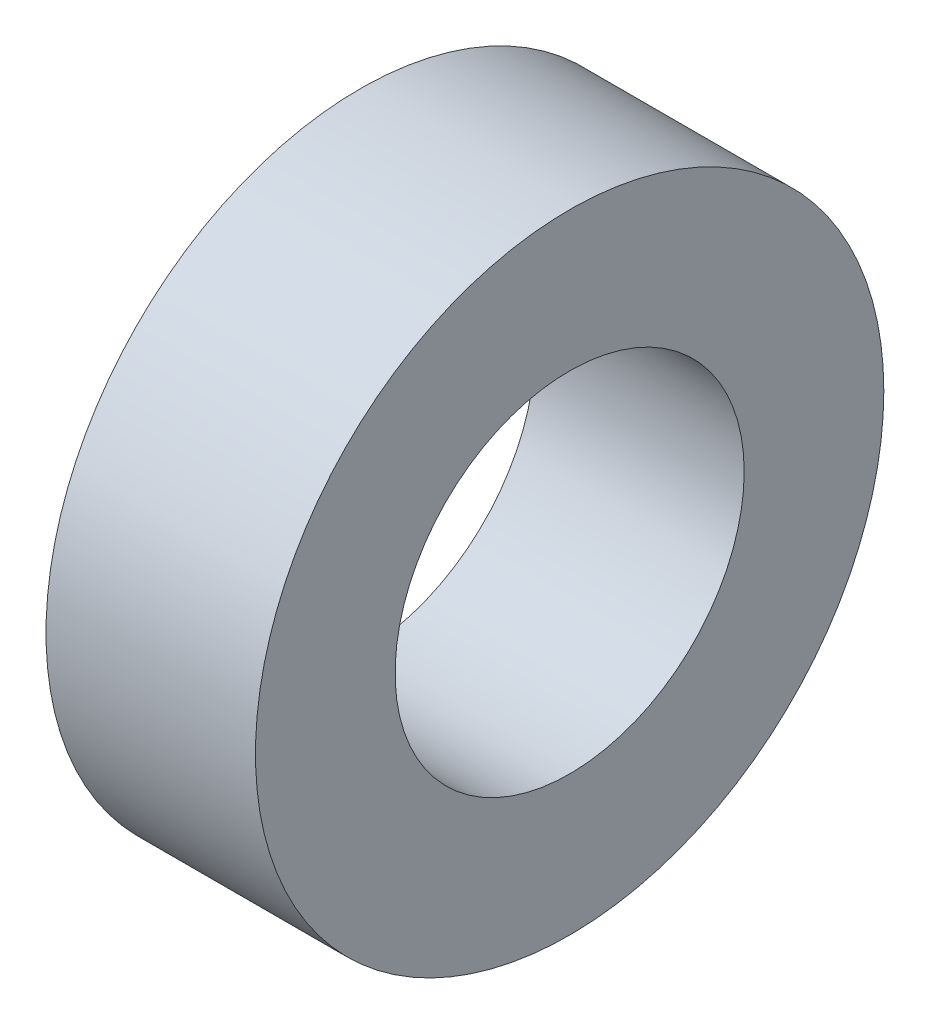
from build123d import *

# Parameters (mm, degrees)
SKETCH_1_R      = 4.5
SKETCH_1_R_2    = 2.5
EXTRUDE_1_DEPTH = 3


with BuildPart() as part:
    # 草图1 → 凸台-拉伸1 (new body)
    with BuildSketch(Plane(origin=(0, 0, 0), x_dir=(0, 0, -1), z_dir=(1, 0, 0))):
        Circle(SKETCH_1_R)
        Circle(SKETCH_1_R_2, mode=Mode.SUBTRACT)
    extrude(amount=EXTRUDE_1_DEPTH)


solid = part.part
